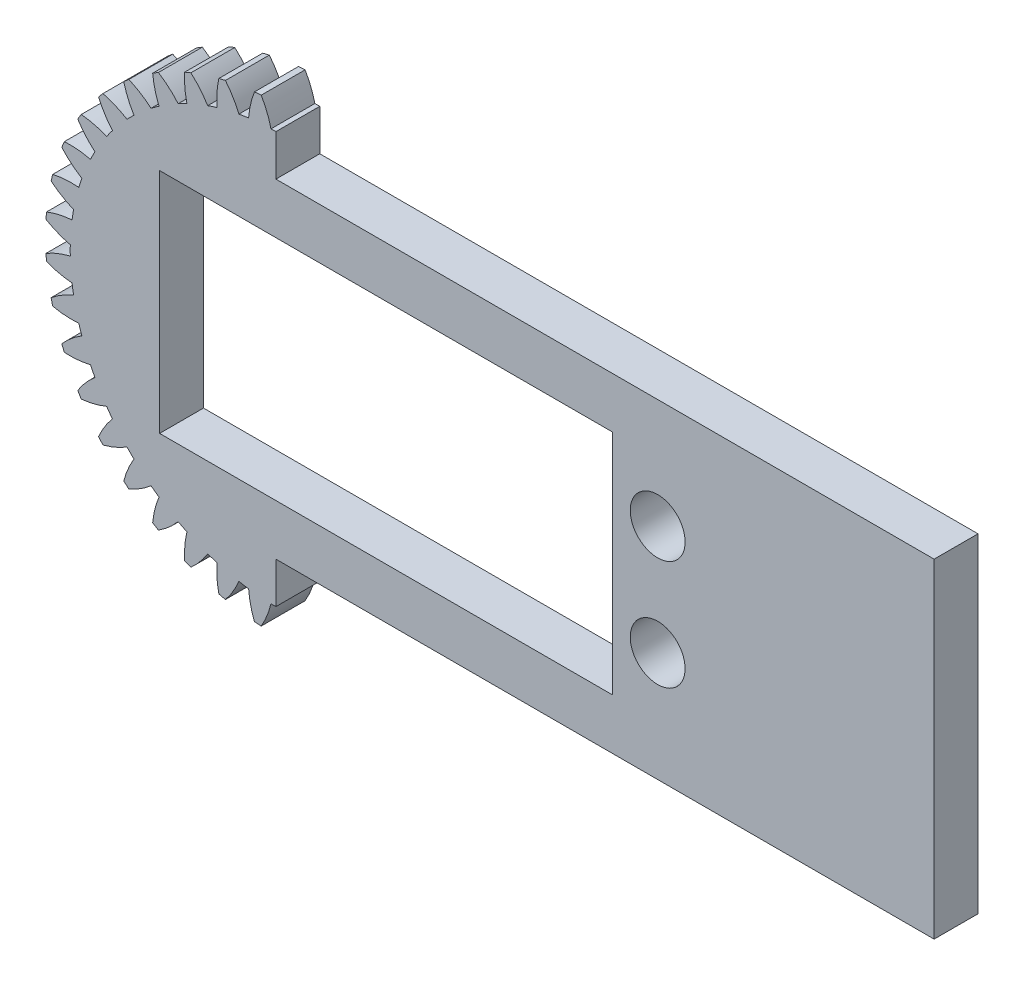
from build123d import *

# Parameters (mm, degrees)
MODEL_R             = 2.5
BOSS_EXTRUDE1_DEPTH = 4
SKETCH3_W           = 38.015783353
SKETCH3_H           = 48.473012512
CUT_EXTRUDE1_DEPTH  = 4
SKETCH4_W           = 60
SKETCH4_H           = 30
BOSS_EXTRUDE2_DEPTH = 4
SKETCH7_W           = 41.3
SKETCH7_H           = 20.75
CUT_EXTRUDE2_DEPTH  = 4
SKETCH8_R           = 2.5
CUT_EXTRUDE3_DEPTH  = 4


with BuildPart() as part:
    # Model → Boss-Extrude1 (new body)
    with BuildSketch(Plane.XY):
        with BuildLine():
            ThreePointArc((99.073084966, 84.908336321), (99.046651001, 84.60128395), (99.024725946, 84.293876719))
            ThreePointArc((99.024725946, 84.293876719), (100.098074623, 83.765095558), (101.23828427, 83.402316207))
            ThreePointArc((101.23828427, 83.402316207), (101.232915009, 82.953642939), (101.23828427, 82.504969672))
            ThreePointArc((101.23828427, 82.504969672), (100.098074623, 82.14219032), (99.024725946, 81.61340916))
            ThreePointArc((99.024725946, 81.61340916), (99.046651001, 81.306001929), (99.073084966, 80.998949557))
            ThreePointArc((99.073084966, 80.998949557), (100.215938537, 80.644587296), (101.398861505, 80.464642447))
            ThreePointArc((101.398861505, 80.464642447), (101.463746311, 80.020653154), (101.53923743, 79.578343736))
            ThreePointArc((101.53923743, 79.578343736), (100.469816849, 79.041662715), (99.492402474, 78.351483002))
            ThreePointArc((99.492402474, 78.351483002), (99.562146681, 78.051290298), (99.636288773, 77.752153434))
            ThreePointArc((99.636288773, 77.752153434), (100.820506391, 77.580935647), (102.017015191, 77.58825614))
            ThreePointArc((102.017015191, 77.58825614), (102.150556385, 77.159883312), (102.29431052, 76.734828869))
            ThreePointArc((102.29431052, 76.734828869), (101.32201169, 76.037461045), (100.464598802, 75.202877295))
            ThreePointArc((100.464598802, 75.202877295), (100.580444826, 74.91729086), (100.700469422, 74.633435245))
            ThreePointArc((100.700469422, 74.633435245), (101.896891719, 74.649577883), (103.077524332, 74.843983462))
            ThreePointArc((103.077524332, 74.843983462), (103.276433687, 74.44177506), (103.484911134, 74.044441844))
            ThreePointArc((103.484911134, 74.044441844), (102.633675279, 73.203558728), (101.917376229, 72.245121162))
            ThreePointArc((101.917376229, 72.245121162), (102.076471558, 71.98117308), (102.239423252, 71.719588183))
            ThreePointArc((102.239423252, 71.719588183), (103.41859034, 71.92269376), (104.554275675, 72.299397515))
            ThreePointArc((104.554275675, 72.299397515), (104.813655381, 71.933257244), (105.081722734, 71.573428918))
            ThreePointArc((105.081722734, 71.573428918), (104.372510105, 70.609735842), (103.814962553, 69.551044374))
            ThreePointArc((103.814962553, 69.551044374), (104.013389731, 69.315233924), (104.215256114, 69.082360832))
            ThreePointArc((104.215256114, 69.082360832), (105.348132986, 69.467428215), (106.410906699, 70.017154449))
            ThreePointArc((106.410906699, 70.017154449), (106.724369968, 69.696097899), (107.045426519, 69.382634629))
            ThreePointArc((107.045426519, 69.382634629), (106.495700285, 68.319860916), (106.110632902, 67.186984044))
            ThreePointArc((106.110632902, 67.186984044), (106.343505994, 66.985117662), (106.579316444, 66.786690483))
            ThreePointArc((106.579316444, 66.786690483), (107.638007912, 67.344238035), (108.601700987, 68.053450665))
            ThreePointArc((108.601700987, 68.053450665), (108.961529314, 67.785383312), (109.327669584, 67.526003605))
            ThreePointArc((109.327669584, 67.526003605), (108.95096583, 66.390318271), (108.747860253, 65.211151183))
            ThreePointArc((108.747860253, 65.211151183), (109.00944515, 65.048199488), (109.273393232, 64.889104159))
            ThreePointArc((109.273393232, 64.889104159), (110.231830798, 65.605403209), (111.072713914, 66.456639064))
            ThreePointArc((111.072713914, 66.456639064), (111.470047129, 66.248161617), (111.872255531, 66.049252262))
            ThreePointArc((111.872255531, 66.049252262), (111.677849953, 64.868619649), (111.661707315, 63.672197352))
            ThreePointArc((111.661707315, 63.672197352), (111.945562929, 63.552172756), (112.231149365, 63.436326732))
            ThreePointArc((112.231149365, 63.436326732), (113.065733115, 64.29373962), (113.763100939, 65.26603845))
            ThreePointArc((113.763100939, 65.26603845), (114.188155381, 65.122284315), (114.616528209, 64.988743121))
            ThreePointArc((114.616528209, 64.988743121), (114.609207717, 63.792234321), (114.780425504, 62.608016704))
            ThreePointArc((114.780425504, 62.608016704), (115.079562368, 62.533874611), (115.379755071, 62.464130405))
            ThreePointArc((115.379755071, 62.464130405), (116.069934785, 63.44154478), (116.606615806, 64.51096536))
            ThreePointArc((116.606615806, 64.51096536), (117.048925224, 64.435474242), (117.492914517, 64.370589435))
            ThreePointArc((117.492914517, 64.370589435), (117.672859366, 63.187666467), (118.027221627, 62.044812896))
            ThreePointArc((118.027221627, 62.044812896), (118.334273999, 62.018378931), (118.641681229, 61.996453876))
            ThreePointArc((118.641681229, 61.996453876), (119.17046239, 63.069802553), (119.533241741, 64.2100122))
            ThreePointArc((119.533241741, 64.2100122), (119.981915009, 64.204642939), (120.430588277, 64.2100122))
            ThreePointArc((120.430588277, 64.2100122), (120.793367628, 63.069802553), (121.322148789, 61.996453876))
            ThreePointArc((121.322148789, 61.996453876), (121.629556019, 62.018378931), (121.936608391, 62.044812896))
            ThreePointArc((121.936608391, 62.044812896), (122.290970652, 63.187666467), (122.470915501, 64.370589435))
            ThreePointArc((122.470915501, 64.370589435), (122.914904794, 64.435474242), (123.357214212, 64.51096536))
            ThreePointArc((123.357214212, 64.51096536), (123.893895234, 63.44154478), (124.584074947, 62.464130405))
            ThreePointArc((124.584074947, 62.464130405), (124.88426765, 62.533874611), (125.183404514, 62.608016704))
            ThreePointArc((125.183404514, 62.608016704), (125.354622301, 63.792234321), (125.347301809, 64.988743121))
            ThreePointArc((125.347301809, 64.988743121), (125.775674637, 65.122284315), (126.200729079, 65.26603845))
            ThreePointArc((126.200729079, 65.26603845), (126.898096903, 64.29373962), (127.732680653, 63.436326732))
            ThreePointArc((127.732680653, 63.436326732), (128.018267089, 63.552172757), (128.302122703, 63.672197352))
            ThreePointArc((128.302122703, 63.672197352), (128.285980065, 64.868619649), (128.091574487, 66.049252262))
            ThreePointArc((128.091574487, 66.049252262), (128.493782889, 66.248161617), (128.891116104, 66.456639065))
            ThreePointArc((128.891116104, 66.456639065), (129.73199922, 65.605403209), (130.690436786, 64.889104159))
            ThreePointArc((130.690436786, 64.889104159), (130.954384868, 65.048199488), (131.215969765, 65.211151183))
            ThreePointArc((131.215969765, 65.211151183), (131.012864188, 66.390318271), (130.636160434, 67.526003605))
            ThreePointArc((130.636160434, 67.526003605), (131.002300704, 67.785383312), (131.362129031, 68.053450665))
            ThreePointArc((131.362129031, 68.053450665), (132.325822106, 67.344238036), (133.384513574, 66.786690483))
            ThreePointArc((133.384513574, 66.786690483), (133.620324024, 66.985117662), (133.853197116, 67.186984044))
            ThreePointArc((133.853197116, 67.186984044), (133.468129733, 68.319860916), (132.918403499, 69.382634629))
            ThreePointArc((132.918403499, 69.382634629), (133.23946005, 69.696097899), (133.552923319, 70.01715445))
            ThreePointArc((133.552923319, 70.01715445), (134.615697032, 69.467428215), (135.748573904, 69.082360832))
            ThreePointArc((135.748573904, 69.082360832), (135.950440287, 69.315233924), (136.148867465, 69.551044374))
            ThreePointArc((136.148867465, 69.551044374), (135.591319913, 70.609735842), (134.882107284, 71.573428918))
            ThreePointArc((134.882107284, 71.573428918), (135.150174637, 71.933257244), (135.409554343, 72.299397515))
            ThreePointArc((135.409554343, 72.299397515), (136.545239678, 71.92269376), (137.724406766, 71.719588183))
            ThreePointArc((137.724406766, 71.719588183), (137.88735846, 71.98117308), (138.046453789, 72.245121162))
            ThreePointArc((138.046453789, 72.245121162), (137.330154739, 73.203558728), (136.478918884, 74.044441844))
            ThreePointArc((136.478918884, 74.044441844), (136.687396331, 74.44177506), (136.886305686, 74.843983462))
            ThreePointArc((136.886305686, 74.843983462), (138.066938299, 74.649577883), (139.263360596, 74.633435245))
            ThreePointArc((139.263360596, 74.633435245), (139.383385192, 74.91729086), (139.499231216, 75.202877295))
            ThreePointArc((139.499231216, 75.202877295), (138.641818328, 76.037461045), (137.669519498, 76.73482887))
            ThreePointArc((137.669519498, 76.73482887), (137.813273633, 77.159883312), (137.946814828, 77.58825614))
            ThreePointArc((137.946814828, 77.58825614), (139.143323627, 77.580935647), (140.327541245, 77.752153434))
            ThreePointArc((140.327541245, 77.752153434), (140.401683337, 78.051290298), (140.471427544, 78.351483002))
            ThreePointArc((140.471427544, 78.351483002), (139.494013169, 79.041662715), (138.424592588, 79.578343736))
            ThreePointArc((138.424592588, 79.578343736), (138.500083707, 80.020653154), (138.564968513, 80.464642447))
            ThreePointArc((138.564968513, 80.464642447), (139.747891481, 80.644587296), (140.890745052, 80.998949557))
            ThreePointArc((140.890745052, 80.998949557), (140.917179017, 81.306001929), (140.939104072, 81.61340916))
            ThreePointArc((140.939104072, 81.61340916), (139.865755396, 82.14219032), (138.725545749, 82.504969672))
            ThreePointArc((138.725545749, 82.504969672), (138.730915009, 82.953642939), (138.725545749, 83.402316207))
            ThreePointArc((138.725545749, 83.402316207), (139.865755396, 83.765095558), (140.939104072, 84.293876719))
            ThreePointArc((140.939104072, 84.293876719), (140.917179017, 84.60128395), (140.890745052, 84.908336321))
            ThreePointArc((140.890745052, 84.908336321), (139.747891481, 85.262698582), (138.564968514, 85.442643432))
            ThreePointArc((138.564968514, 85.442643432), (138.500083707, 85.886632724), (138.424592588, 86.328942142))
            ThreePointArc((138.424592588, 86.328942142), (139.494013169, 86.865623164), (140.471427544, 87.555802877))
            ThreePointArc((140.471427544, 87.555802877), (140.401683337, 87.85599558), (140.327541245, 88.155132445))
            ThreePointArc((140.327541245, 88.155132445), (139.143323627, 88.326350231), (137.946814828, 88.319029739))
            ThreePointArc((137.946814828, 88.319029739), (137.813273633, 88.747402567), (137.669519498, 89.172457009))
            ThreePointArc((137.669519498, 89.172457009), (138.641818328, 89.869824833), (139.499231216, 90.704408584))
            ThreePointArc((139.499231216, 90.704408584), (139.383385192, 90.989995019), (139.263360596, 91.273850633))
            ThreePointArc((139.263360596, 91.273850633), (138.066938299, 91.257707996), (136.886305686, 91.063302417))
            ThreePointArc((136.886305686, 91.063302417), (136.687396331, 91.465510819), (136.478918884, 91.862844035))
            ThreePointArc((136.478918884, 91.862844035), (137.330154739, 92.703727151), (138.046453789, 93.662164717))
            ThreePointArc((138.046453789, 93.662164717), (137.88735846, 93.926112798), (137.724406766, 94.187697696))
            ThreePointArc((137.724406766, 94.187697696), (136.545239678, 93.984592119), (135.409554344, 93.607888364))
            ThreePointArc((135.409554344, 93.607888364), (135.150174637, 93.974028635), (134.882107284, 94.333856961))
            ThreePointArc((134.882107284, 94.333856961), (135.591319913, 95.297550036), (136.148867465, 96.356241504))
            ThreePointArc((136.148867465, 96.356241504), (135.950440287, 96.592051954), (135.748573904, 96.824925046))
            ThreePointArc((135.748573904, 96.824925046), (134.615697032, 96.439857663), (133.552923319, 95.890131429))
            ThreePointArc((133.552923319, 95.890131429), (133.23946005, 96.21118798), (132.918403499, 96.524651249))
            ThreePointArc((132.918403499, 96.524651249), (133.468129733, 97.587424962), (133.853197116, 98.720301834))
            ThreePointArc((133.853197116, 98.720301834), (133.620324024, 98.922168217), (133.384513574, 99.120595395))
            ThreePointArc((133.384513574, 99.120595395), (132.325822106, 98.563047843), (131.362129031, 97.853835214))
            ThreePointArc((131.362129031, 97.853835214), (131.002300704, 98.121902567), (130.636160434, 98.381282274))
            ThreePointArc((130.636160434, 98.381282274), (131.012864188, 99.516967608), (131.215969765, 100.696134696))
            ThreePointArc((131.215969765, 100.696134696), (130.954384868, 100.859086391), (130.690436786, 101.01818172))
            ThreePointArc((130.690436786, 101.01818172), (129.73199922, 100.30188267), (128.891116104, 99.450646814))
            ThreePointArc((128.891116104, 99.450646814), (128.493782889, 99.659124261), (128.091574487, 99.858033616))
            ThreePointArc((128.091574487, 99.858033616), (128.285980065, 101.03866623), (128.302122703, 102.235088526))
            ThreePointArc((128.302122703, 102.235088526), (128.018267089, 102.355113122), (127.732680653, 102.470959146))
            ThreePointArc((127.732680653, 102.470959146), (126.898096903, 101.613546259), (126.200729079, 100.641247429))
            ThreePointArc((126.200729079, 100.641247429), (125.775674637, 100.785001563), (125.347301809, 100.918542758))
            ThreePointArc((125.347301809, 100.918542758), (125.354622301, 102.115051557), (125.183404514, 103.299269175))
            ThreePointArc((125.183404514, 103.299269175), (124.88426765, 103.373411268), (124.584074947, 103.443155474))
            ThreePointArc((124.584074947, 103.443155474), (123.893895234, 102.465741099), (123.357214212, 101.396320519))
            ThreePointArc((123.357214212, 101.396320519), (122.914904794, 101.471811637), (122.470915501, 101.536696444))
            ThreePointArc((122.470915501, 101.536696444), (122.290970652, 102.719619412), (121.936608391, 103.862472983))
            ThreePointArc((121.936608391, 103.862472983), (121.629556019, 103.888906948), (121.322148789, 103.910832002))
            ThreePointArc((121.322148789, 103.910832002), (120.793367628, 102.837483326), (120.430588277, 101.697273679))
            ThreePointArc((120.430588277, 101.697273679), (119.981915009, 101.702642939), (119.533241741, 101.697273679))
            ThreePointArc((119.533241741, 101.697273679), (119.17046239, 102.837483326), (118.641681229, 103.910832002))
            ThreePointArc((118.641681229, 103.910832002), (118.334273999, 103.888906948), (118.027221627, 103.862472983))
            ThreePointArc((118.027221627, 103.862472983), (117.672859366, 102.719619412), (117.492914517, 101.536696444))
            ThreePointArc((117.492914517, 101.536696444), (117.048925224, 101.471811637), (116.606615806, 101.396320519))
            ThreePointArc((116.606615806, 101.396320519), (116.069934785, 102.465741099), (115.379755071, 103.443155474))
            ThreePointArc((115.379755071, 103.443155474), (115.079562368, 103.373411268), (114.780425504, 103.299269175))
            ThreePointArc((114.780425504, 103.299269175), (114.609207717, 102.115051557), (114.616528209, 100.918542758))
            ThreePointArc((114.616528209, 100.918542758), (114.188155382, 100.785001563), (113.763100939, 100.641247428))
            ThreePointArc((113.763100939, 100.641247428), (113.065733115, 101.613546258), (112.231149365, 102.470959146))
            ThreePointArc((112.231149365, 102.470959146), (111.945562929, 102.355113122), (111.661707315, 102.235088526))
            ThreePointArc((111.661707315, 102.235088526), (111.677849953, 101.03866623), (111.872255532, 99.858033616))
            ThreePointArc((111.872255532, 99.858033616), (111.470047129, 99.659124261), (111.072713914, 99.450646814))
            ThreePointArc((111.072713914, 99.450646814), (110.231830798, 100.30188267), (109.273393232, 101.018181719))
            ThreePointArc((109.273393232, 101.018181719), (109.00944515, 100.859086391), (108.747860253, 100.696134696))
            ThreePointArc((108.747860253, 100.696134696), (108.95096583, 99.516967608), (109.327669585, 98.381282274))
            ThreePointArc((109.327669585, 98.381282274), (108.961529314, 98.121902567), (108.601700987, 97.853835214))
            ThreePointArc((108.601700987, 97.853835214), (107.638007912, 98.563047843), (106.579316444, 99.120595395))
            ThreePointArc((106.579316444, 99.120595395), (106.343505994, 98.922168217), (106.110632902, 98.720301834))
            ThreePointArc((106.110632902, 98.720301834), (106.495700285, 97.587424962), (107.045426519, 96.524651249))
            ThreePointArc((107.045426519, 96.524651249), (106.724369969, 96.21118798), (106.410906699, 95.890131429))
            ThreePointArc((106.410906699, 95.890131429), (105.348132986, 96.439857663), (104.215256114, 96.824925046))
            ThreePointArc((104.215256114, 96.824925046), (104.013389732, 96.592051954), (103.814962553, 96.356241504))
            ThreePointArc((103.814962553, 96.356241504), (104.372510105, 95.297550036), (105.081722735, 94.333856961))
            ThreePointArc((105.081722735, 94.333856961), (104.813655382, 93.974028635), (104.554275675, 93.607888364))
            ThreePointArc((104.554275675, 93.607888364), (103.418590341, 93.984592119), (102.239423253, 94.187697696))
            ThreePointArc((102.239423253, 94.187697696), (102.076471558, 93.926112798), (101.917376229, 93.662164717))
            ThreePointArc((101.917376229, 93.662164717), (102.633675279, 92.703727151), (103.484911134, 91.862844034))
            ThreePointArc((103.484911134, 91.862844034), (103.276433687, 91.465510819), (103.077524332, 91.063302417))
            ThreePointArc((103.077524332, 91.063302417), (101.896891719, 91.257707996), (100.700469422, 91.273850633))
            ThreePointArc((100.700469422, 91.273850633), (100.580444826, 90.989995019), (100.464598802, 90.704408584))
            ThreePointArc((100.464598802, 90.704408584), (101.32201169, 89.869824833), (102.29431052, 89.172457009))
            ThreePointArc((102.29431052, 89.172457009), (102.150556385, 88.747402567), (102.017015191, 88.319029739))
            ThreePointArc((102.017015191, 88.319029739), (100.820506391, 88.326350231), (99.636288773, 88.155132445))
            ThreePointArc((99.636288773, 88.155132445), (99.562146681, 87.85599558), (99.492402474, 87.555802877))
            ThreePointArc((99.492402474, 87.555802877), (100.469816849, 86.865623164), (101.53923743, 86.328942142))
            ThreePointArc((101.53923743, 86.328942142), (101.463746311, 85.886632724), (101.398861505, 85.442643432))
            ThreePointArc((101.398861505, 85.442643432), (100.215938537, 85.262698582), (99.073084966, 84.908336321))
        make_face()
        with Locations((119.981915009, 82.953642939)):
            Circle(MODEL_R, mode=Mode.SUBTRACT)
    extrude(amount=BOSS_EXTRUDE1_DEPTH)

    # Sketch3 → Cut-Extrude1 (cut)
    with BuildSketch(Plane.XY.offset(4)):
        with Locations((138.989806686, 82.953642939)):
            Rectangle(SKETCH3_W, SKETCH3_H)
    extrude(amount=-CUT_EXTRUDE1_DEPTH, mode=Mode.SUBTRACT)

    # Sketch4 → Boss-Extrude2 (add)
    with BuildSketch(Plane.XY):
        with Locations((149.981915009, 82.953642939)):
            Rectangle(SKETCH4_W, SKETCH4_H)
    extrude(amount=BOSS_EXTRUDE2_DEPTH)

    # Sketch7 → Cut-Extrude2 (cut)
    with BuildSketch(Plane.XY.offset(4)):
        with Locations((130.031915009, 82.953642939)):
            Rectangle(SKETCH7_W, SKETCH7_H)
    extrude(amount=-CUT_EXTRUDE2_DEPTH, mode=Mode.SUBTRACT)

    # Sketch8 → Cut-Extrude3 (cut)
    with BuildSketch(Plane.XY.offset(4)):
        with Locations((154.781915009, 77.953642939)):
            Circle(SKETCH8_R)
        with Locations((154.781915009, 87.953642939)):
            Circle(SKETCH8_R)
    extrude(amount=-CUT_EXTRUDE3_DEPTH, mode=Mode.SUBTRACT)


solid = part.part
